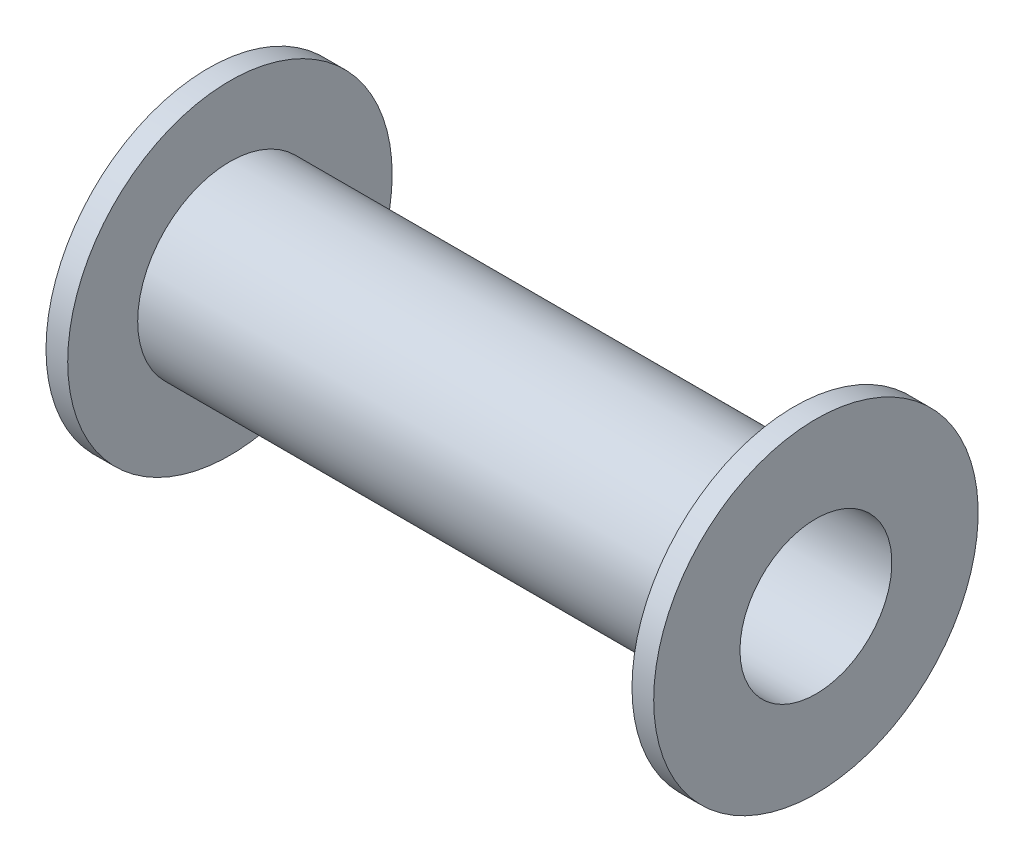
from build123d import *

# Parameters (mm, degrees)
ESBO_O2_R             = 14.95
ESBO_O2_R_2           = 8.5
CORTE_EXTRUS_O1_DEPTH = 1
ESBO_O3_R             = 14.95
ESBO_O3_R_2           = 8.5
CORTE_EXTRUS_O2_DEPTH = 1


with BuildPart() as part:
    # Esboço1 → Revolução1 (revolve)
    with BuildSketch(Plane(origin=(0, 0, 0), x_dir=(1, 0, 0), z_dir=(0, 1, 0))):
        Polygon((-56, -7), (-56, -14.95), (-53, -14.95), (-53, -8.5), (-3, -8.5), (-3, -14.95), (0, -14.95), (0, -7), align=None)
    revolve(axis=Axis((-102.959505757, 0, 0), (1, 0, 0)))

    # Esboço2 → Corte-extrusão1 (cut)
    with BuildSketch(Plane(origin=(-53, 0, 0), x_dir=(0, 0, -1), z_dir=(1, 0, 0))):
        Circle(ESBO_O2_R)
        Circle(ESBO_O2_R_2, mode=Mode.SUBTRACT)
    extrude(amount=-CORTE_EXTRUS_O1_DEPTH, mode=Mode.SUBTRACT)

    # Esboço3 → Corte-extrusão2 (cut)
    with BuildSketch(Plane.ZY.offset(3)):
        Circle(ESBO_O3_R)
        Circle(ESBO_O3_R_2, mode=Mode.SUBTRACT)
    extrude(amount=-CORTE_EXTRUS_O2_DEPTH, mode=Mode.SUBTRACT)


solid = part.part
